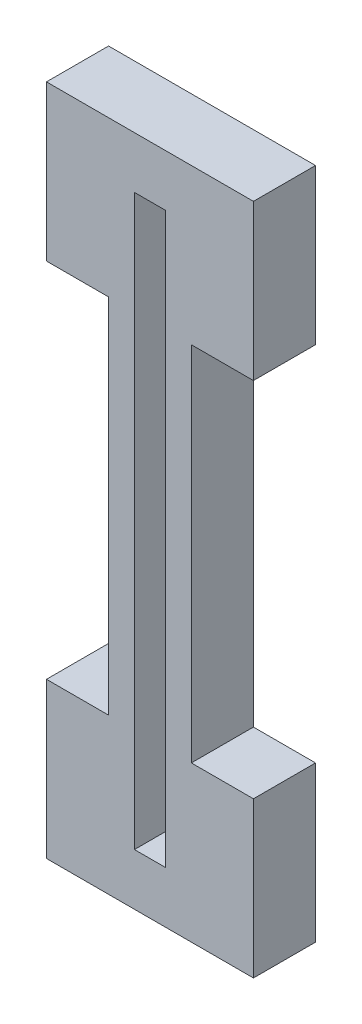
from build123d import *

# Parameters (mm, degrees)
SKETCH1_W           = 3
SKETCH1_H           = 55
BOSS_EXTRUDE1_DEPTH = 6


with BuildPart() as part:
    # Sketch1 → Boss-Extrude1 (new body)
    with BuildSketch(Plane.XY):
        Polygon((0, 0), (20, 0), (20, 15), (14, 15), (14, 50), (20, 50), (20, 65), (0, 65), (0, 50), (6, 50), (6, 15), (0, 15), align=None)
        with Locations((10, 32.5)):
            Rectangle(SKETCH1_W, SKETCH1_H, mode=Mode.SUBTRACT)
    extrude(amount=BOSS_EXTRUDE1_DEPTH)


solid = part.part
